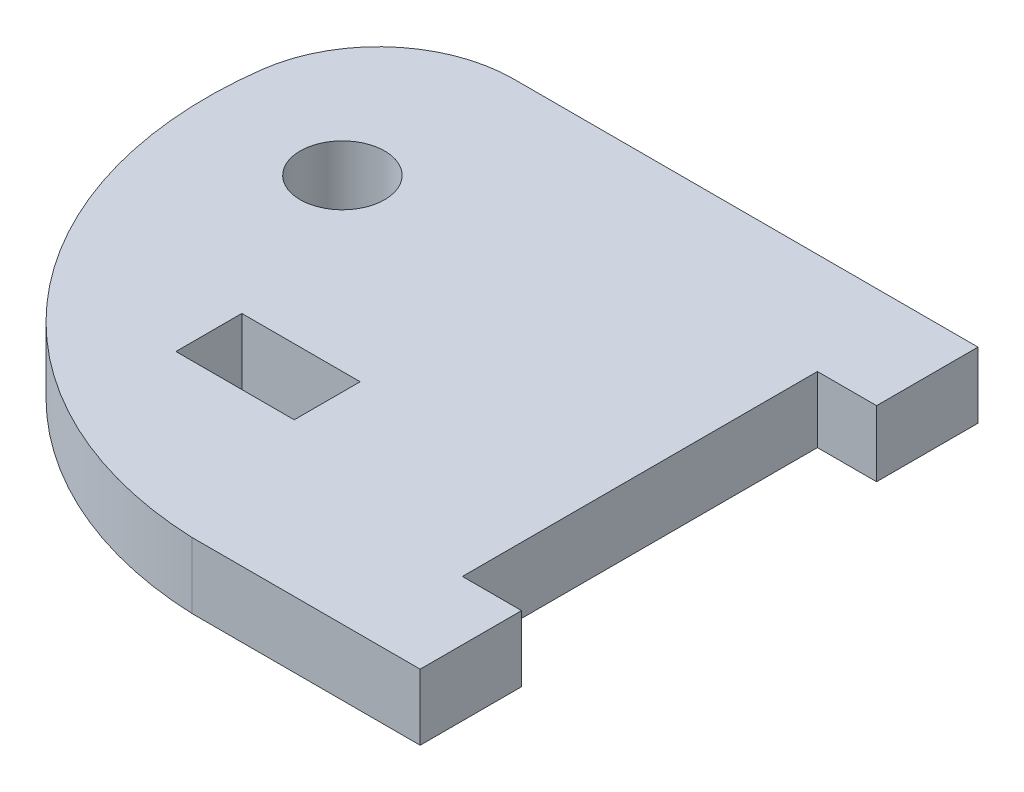
from build123d import *

# Parameters (mm, degrees)
SKETCH1_R           = 3.175
SKETCH1_W           = 8.89
SKETCH1_H           = 4.953
BOSS_EXTRUDE1_DEPTH = 2.4765


with BuildPart() as part:
    # Sketch1 → Boss-Extrude1 (new, symmetric)
    with BuildSketch(Plane(origin=(0, 0, 0), x_dir=(1, 0, 0), z_dir=(0, 1, 0))):
        with BuildLine():
            Line((30.607, -21.59), (30.607, 5.08))
            Line((30.607, 5.08), (35.052, 5.08))
            Line((35.052, 5.08), (35.052, 12.7))
            Line((35.052, 12.7), (0.169883273, 12.7))
            ThreePointArc((0.169883273, 12.7), (-6.518875251, 10.18762116), (-9.899622874, 3.893013664))
            ThreePointArc((-9.899622874, 3.893013664), (-3.310755736, -18.802646574), (17.907, -29.21))
            Line((17.907, -29.21), (35.052, -29.21))
            Line((35.052, -29.21), (35.052, -21.59))
            Line((35.052, -21.59), (30.607, -21.59))
        make_face()
        Circle(SKETCH1_R, mode=Mode.SUBTRACT)
        with Locations((9.652, -15.24)):
            Rectangle(SKETCH1_W, SKETCH1_H, mode=Mode.SUBTRACT)
    extrude(amount=BOSS_EXTRUDE1_DEPTH, both=True)


solid = part.part
